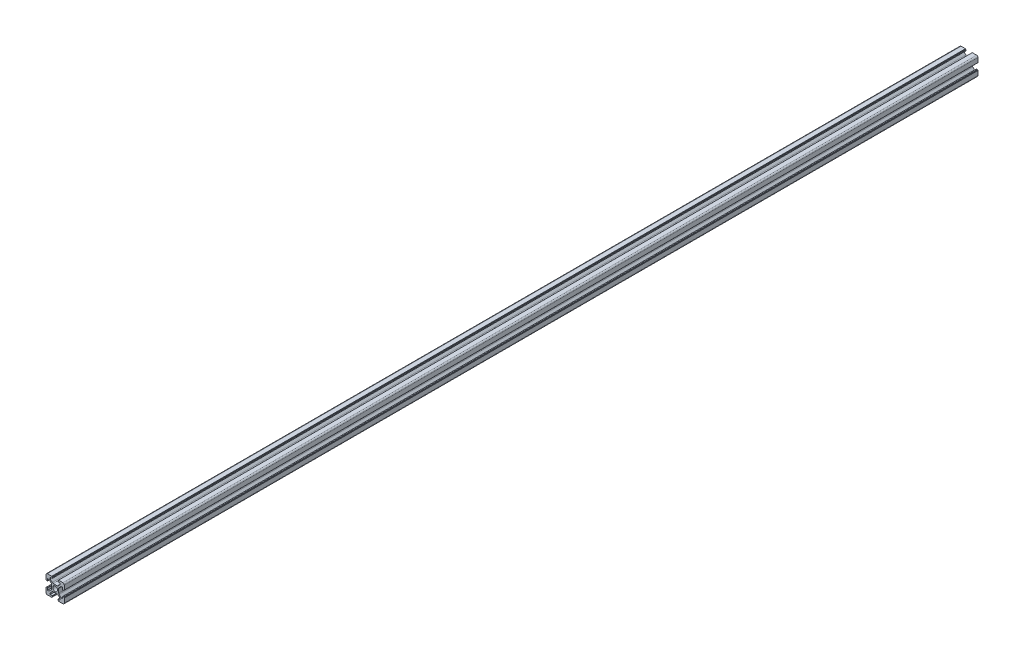
from build123d import *

# Parameters (mm, degrees)
SKETCH_3_R      = 2.6
EXTRUDE_1_DEPTH = 1000


with BuildPart() as part:
    # Эскиз3 → Бобышка-Вытянуть1 (new body)
    with BuildSketch(Plane.XY):
        with BuildLine():
            Line((-10, 5.5), (-10, 8.5))
            ThreePointArc((-10, 8.5), (-9.560660172, 9.560660172), (-8.5, 10))
            Line((-8.5, 10), (-5.5, 10))
            Line((-5.5, 10), (-3.75, 10))
            ThreePointArc((-3.75, 10), (-3.643933983, 9.956066017), (-3.6, 9.85))
            Line((-3.6, 9.85), (-3.6, 9.65))
            ThreePointArc((-3.6, 9.65), (-3.556066017, 9.543933983), (-3.45, 9.5))
            Line((-3.45, 9.5), (-3.25, 9.5))
            ThreePointArc((-3.25, 9.5), (-3.143933983, 9.456066017), (-3.1, 9.35))
            Line((-3.1, 9.35), (-3.1, 8.35))
            ThreePointArc((-3.1, 8.35), (-3.143933983, 8.243933983), (-3.25, 8.2))
            Line((-3.25, 8.2), (-5.5, 8.2))
            Line((-5.5, 8.2), (-5.5, 6.6))
            Line((-5.5, 6.6), (-3.239339828, 4.339339828))
            ThreePointArc((-3.239339828, 4.339339828), (-2.752704805, 4.014180701), (-2.178679656, 3.9))
            Line((-2.178679656, 3.9), (2.178679656, 3.9))
            ThreePointArc((2.178679656, 3.9), (2.752704805, 4.014180701), (3.239339828, 4.339339828))
            Line((3.239339828, 4.339339828), (5.5, 6.6))
            Line((5.5, 6.6), (5.5, 8.2))
            Line((5.5, 8.2), (3.25, 8.2))
            ThreePointArc((3.25, 8.2), (3.143933983, 8.243933983), (3.1, 8.35))
            Line((3.1, 8.35), (3.1, 9.35))
            ThreePointArc((3.1, 9.35), (3.143933983, 9.456066017), (3.25, 9.5))
            Line((3.25, 9.5), (3.45, 9.5))
            ThreePointArc((3.45, 9.5), (3.556066017, 9.543933983), (3.6, 9.65))
            Line((3.6, 9.65), (3.6, 9.85))
            ThreePointArc((3.6, 9.85), (3.643933983, 9.956066017), (3.75, 10))
            Line((3.75, 10), (5.5, 10))
            Line((5.5, 10), (8.5, 10))
            ThreePointArc((8.5, 10), (9.560660172, 9.560660172), (10, 8.5))
            Line((10, 8.5), (10, 5.5))
            Line((10, 5.5), (10, 3.75))
            ThreePointArc((10, 3.75), (9.956066017, 3.643933983), (9.85, 3.6))
            Line((9.85, 3.6), (9.65, 3.6))
            ThreePointArc((9.65, 3.6), (9.543933983, 3.556066017), (9.5, 3.45))
            Line((9.5, 3.45), (9.5, 3.25))
            ThreePointArc((9.5, 3.25), (9.456066017, 3.143933983), (9.35, 3.1))
            Line((9.35, 3.1), (8.35, 3.1))
            ThreePointArc((8.35, 3.1), (8.243933983, 3.143933983), (8.2, 3.25))
            Line((8.2, 3.25), (8.2, 5.5))
            Line((8.2, 5.5), (6.6, 5.5))
            Line((6.6, 5.5), (4.339339828, 3.239339828))
            ThreePointArc((4.339339828, 3.239339828), (4.014180701, 2.752704805), (3.9, 2.178679656))
            Line((3.9, 2.178679656), (3.9, -2.178679656))
            ThreePointArc((3.9, -2.178679656), (4.014180701, -2.752704805), (4.339339828, -3.239339828))
            Line((4.339339828, -3.239339828), (6.6, -5.5))
            Line((6.6, -5.5), (8.2, -5.5))
            Line((8.2, -5.5), (8.2, -3.25))
            ThreePointArc((8.2, -3.25), (8.243933983, -3.143933983), (8.35, -3.1))
            Line((8.35, -3.1), (9.35, -3.1))
            ThreePointArc((9.35, -3.1), (9.456066017, -3.143933983), (9.5, -3.25))
            Line((9.5, -3.25), (9.5, -3.45))
            ThreePointArc((9.5, -3.45), (9.543933983, -3.556066017), (9.65, -3.6))
            Line((9.65, -3.6), (9.85, -3.6))
            ThreePointArc((9.85, -3.6), (9.956066017, -3.643933983), (10, -3.75))
            Line((10, -3.75), (10, -5.5))
            Line((10, -5.5), (10, -8.5))
            ThreePointArc((10, -8.5), (9.560660172, -9.560660172), (8.5, -10))
            Line((8.5, -10), (5.5, -10))
            Line((5.5, -10), (3.75, -10))
            ThreePointArc((3.75, -10), (3.643933983, -9.956066017), (3.6, -9.85))
            Line((3.6, -9.85), (3.6, -9.65))
            ThreePointArc((3.6, -9.65), (3.556066017, -9.543933983), (3.45, -9.5))
            Line((3.45, -9.5), (3.25, -9.5))
            ThreePointArc((3.25, -9.5), (3.143933983, -9.456066017), (3.1, -9.35))
            Line((3.1, -9.35), (3.1, -8.35))
            ThreePointArc((3.1, -8.35), (3.143933983, -8.243933983), (3.25, -8.2))
            Line((3.25, -8.2), (5.5, -8.2))
            Line((5.5, -8.2), (5.5, -6.6))
            Line((5.5, -6.6), (3.239339828, -4.339339828))
            ThreePointArc((3.239339828, -4.339339828), (2.752704805, -4.014180701), (2.178679656, -3.9))
            Line((2.178679656, -3.9), (-2.178679656, -3.9))
            ThreePointArc((-2.178679656, -3.9), (-2.752704805, -4.014180701), (-3.239339828, -4.339339828))
            Line((-3.239339828, -4.339339828), (-5.5, -6.6))
            Line((-5.5, -6.6), (-5.5, -8.2))
            Line((-5.5, -8.2), (-3.25, -8.2))
            ThreePointArc((-3.25, -8.2), (-3.143933983, -8.243933983), (-3.1, -8.35))
            Line((-3.1, -8.35), (-3.1, -9.35))
            ThreePointArc((-3.1, -9.35), (-3.143933983, -9.456066017), (-3.25, -9.5))
            Line((-3.25, -9.5), (-3.45, -9.5))
            ThreePointArc((-3.45, -9.5), (-3.556066017, -9.543933983), (-3.6, -9.65))
            Line((-3.6, -9.65), (-3.6, -9.85))
            ThreePointArc((-3.6, -9.85), (-3.643933983, -9.956066017), (-3.75, -10))
            Line((-3.75, -10), (-5.5, -10))
            Line((-5.5, -10), (-8.5, -10))
            ThreePointArc((-8.5, -10), (-9.560660172, -9.560660172), (-10, -8.5))
            Line((-10, -8.5), (-10, -5.5))
            Line((-10, -5.5), (-10, -3.75))
            ThreePointArc((-10, -3.75), (-9.956066017, -3.643933983), (-9.85, -3.6))
            Line((-9.85, -3.6), (-9.65, -3.6))
            ThreePointArc((-9.65, -3.6), (-9.543933983, -3.556066017), (-9.5, -3.45))
            Line((-9.5, -3.45), (-9.5, -3.25))
            ThreePointArc((-9.5, -3.25), (-9.456066017, -3.143933983), (-9.35, -3.1))
            Line((-9.35, -3.1), (-8.35, -3.1))
            ThreePointArc((-8.35, -3.1), (-8.243933983, -3.143933983), (-8.2, -3.25))
            Line((-8.2, -3.25), (-8.2, -5.5))
            Line((-8.2, -5.5), (-6.6, -5.5))
            Line((-6.6, -5.5), (-4.339339828, -3.239339828))
            ThreePointArc((-4.339339828, -3.239339828), (-4.014180701, -2.752704805), (-3.9, -2.178679656))
            Line((-3.9, -2.178679656), (-3.9, 2.178679656))
            ThreePointArc((-3.9, 2.178679656), (-4.014180701, 2.752704805), (-4.339339828, 3.239339828))
            Line((-4.339339828, 3.239339828), (-6.6, 5.5))
            Line((-6.6, 5.5), (-8.2, 5.5))
            Line((-8.2, 5.5), (-8.2, 3.25))
            ThreePointArc((-8.2, 3.25), (-8.243933983, 3.143933983), (-8.35, 3.1))
            Line((-8.35, 3.1), (-9.35, 3.1))
            ThreePointArc((-9.35, 3.1), (-9.456066017, 3.143933983), (-9.5, 3.25))
            Line((-9.5, 3.25), (-9.5, 3.45))
            ThreePointArc((-9.5, 3.45), (-9.543933983, 3.556066017), (-9.65, 3.6))
            Line((-9.65, 3.6), (-9.85, 3.6))
            ThreePointArc((-9.85, 3.6), (-9.956066017, 3.643933983), (-10, 3.75))
            Line((-10, 3.75), (-10, 5.5))
        make_face()
        Circle(SKETCH_3_R, mode=Mode.SUBTRACT)
    extrude(amount=EXTRUDE_1_DEPTH)


solid = part.part
